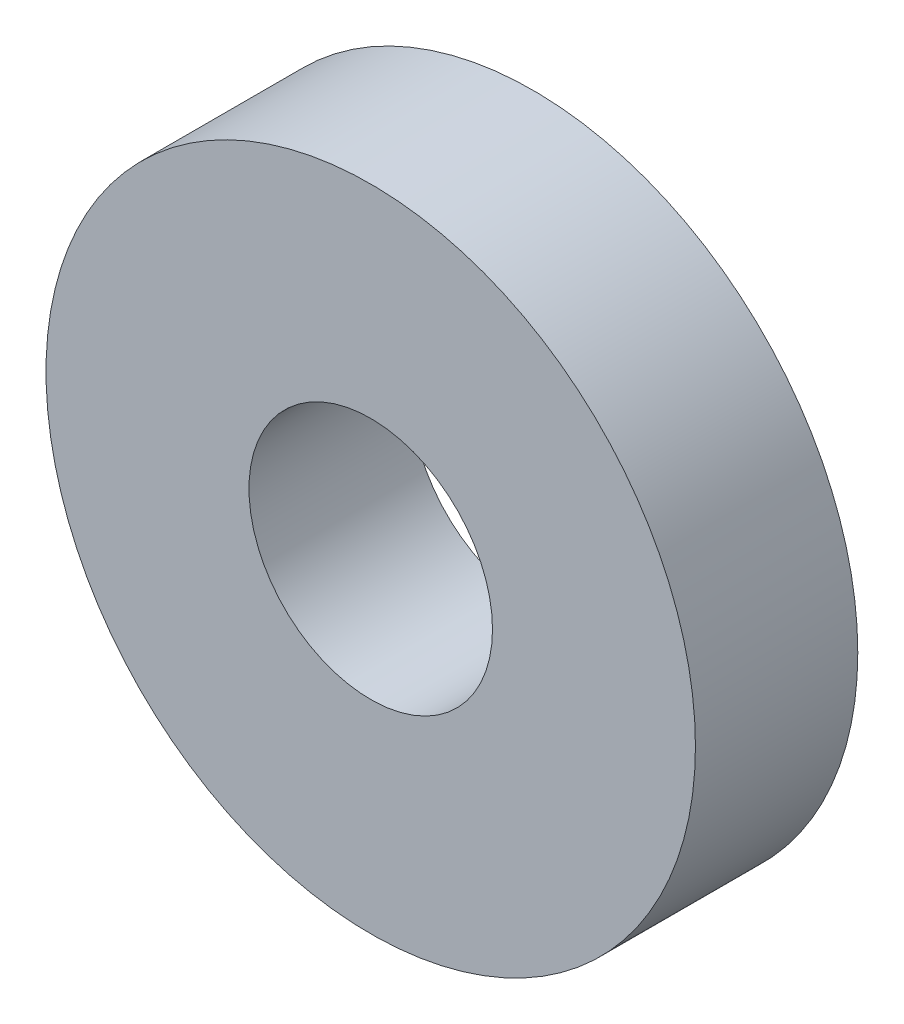
from build123d import *

# Parameters (mm, degrees)
ESBO_O1_R                = 8
ESBO_O1_R_2              = 3
RESSALTO_EXTRUS_O1_DEPTH = 4


with BuildPart() as part:
    # Esboço1 → Ressalto-extrusão1 (new body)
    with BuildSketch(Plane.XY):
        Circle(ESBO_O1_R)
        Circle(ESBO_O1_R_2, mode=Mode.SUBTRACT)
    extrude(amount=RESSALTO_EXTRUS_O1_DEPTH)


solid = part.part
